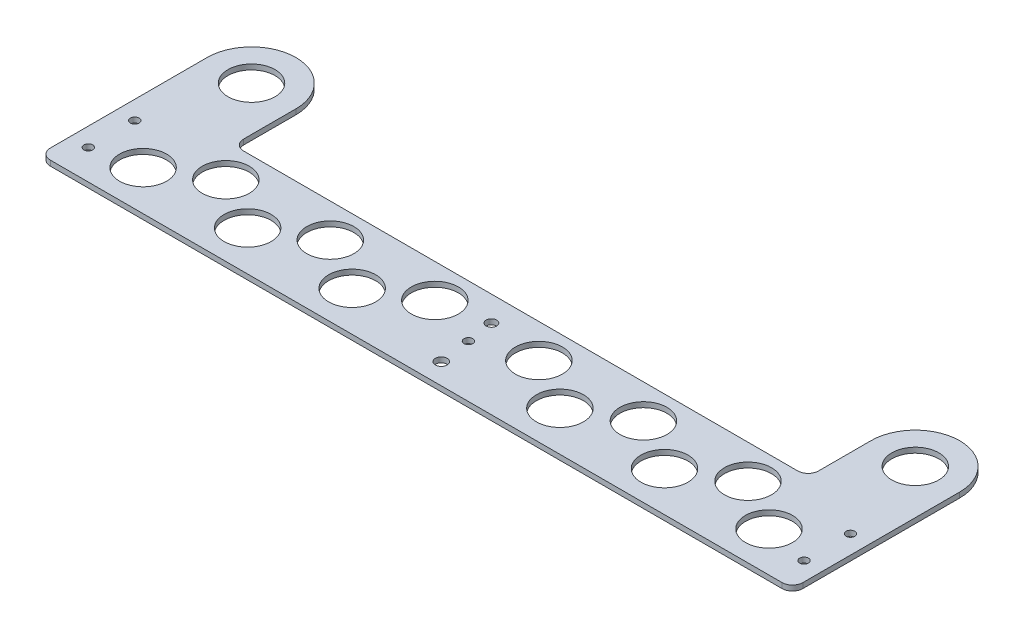
from build123d import *

# Parameters (mm, degrees)
SKETCH1_R           = 14.2875
BOSS_EXTRUDE1_DEPTH = 3.175
CUT_EXTRUDE1_REACH  = 5.175
SKETCH2_R           = 3.556
SKETCH2_R_2         = 3.175
CUT_EXTRUDE2_REACH  = 5.175
SKETCH3_R           = 2.667
CUT_EXTRUDE3_REACH  = 5.175
SKETCH4_R           = 2.667
CUT_EXTRUDE4_REACH  = 5.175
SKETCH6_R           = 14.2875


with BuildPart() as part:
    # Sketch1 → Boss-Extrude1 (new body)
    with BuildSketch(Plane(origin=(0, 0, 0), x_dir=(1, 0, 0), z_dir=(0, 1, 0))):
        with BuildLine():
            Line((-26.9875, 0), (-26.9875, -95.25))
            ThreePointArc((-26.9875, -95.25), (-25.127628061, -99.740128061), (-20.6375, -101.6))
            Line((-20.6375, -101.6), (423.8625, -101.6))
            ThreePointArc((423.8625, -101.6), (428.352628061, -99.740128061), (430.2125, -95.25))
            Line((430.2125, -95.25), (430.2125, 0))
            ThreePointArc((430.2125, 0), (403.225, 26.9875), (376.2375, 0))
            Line((376.2375, 0), (376.2375, -31.75))
            ThreePointArc((376.2375, -31.75), (374.377628061, -36.240128061), (369.8875, -38.1))
            Line((369.8875, -38.1), (33.3375, -38.1))
            ThreePointArc((33.3375, -38.1), (28.847371939, -36.240128061), (26.9875, -31.75))
            Line((26.9875, -31.75), (26.9875, 0))
            ThreePointArc((26.9875, 0), (0, 26.9875), (-26.9875, 0))
        make_face()
        Circle(SKETCH1_R, mode=Mode.SUBTRACT)
        with Locations((403.225, 0)):
            Circle(SKETCH1_R, mode=Mode.SUBTRACT)
    extrude(amount=BOSS_EXTRUDE1_DEPTH)

    # Sketch2 → Cut-Extrude1 (cut, up to next)
    with BuildSketch(Plane(origin=(0, 3.175, 0), x_dir=(1, 0, 0), z_dir=(0, 1, 0)), mode=Mode.PRIVATE) as cut_extrude1_sk1:
        with Locations((204.1525, -88.9)):
            Circle(SKETCH2_R)
    cut_extrude1_tool1 = extrude(cut_extrude1_sk1.sketch, amount=-CUT_EXTRUDE1_REACH, mode=Mode.PRIVATE) & part.part
    add(cut_extrude1_tool1.solids().sort_by_distance((204.1525, 3.175, 88.9))[0], mode=Mode.SUBTRACT)
    # Sketch2 → Cut-Extrude1 (cut, up to next)
    with BuildSketch(Plane(origin=(0, 3.175, 0), x_dir=(1, 0, 0), z_dir=(0, 1, 0)), mode=Mode.PRIVATE) as cut_extrude1_sk2:
        with Locations((199.0725, -53.34)):
            Circle(SKETCH2_R_2)
    cut_extrude1_tool2 = extrude(cut_extrude1_sk2.sketch, amount=-CUT_EXTRUDE1_REACH, mode=Mode.PRIVATE) & part.part
    add(cut_extrude1_tool2.solids().sort_by_distance((199.0725, 3.175, 53.34))[0], mode=Mode.SUBTRACT)

    # Sketch3 → Cut-Extrude2 (cut, up to next)
    with BuildSketch(Plane(origin=(0, 3.175, 0), x_dir=(1, 0, 0), z_dir=(0, 1, 0)), mode=Mode.PRIVATE) as cut_extrude2_sk1:
        with Locations((-15.779743521, -55.159030044)):
            Circle(SKETCH3_R)
    cut_extrude2_tool1 = extrude(cut_extrude2_sk1.sketch, amount=-CUT_EXTRUDE2_REACH, mode=Mode.PRIVATE) & part.part
    add(cut_extrude2_tool1.solids().sort_by_distance((-15.779744, 3.175, 55.15903))[0], mode=Mode.SUBTRACT)
    # Sketch3 → Cut-Extrude2 (cut, up to next)
    with BuildSketch(Plane(origin=(0, 3.175, 0), x_dir=(1, 0, 0), z_dir=(0, 1, 0)), mode=Mode.PRIVATE) as cut_extrude2_sk2:
        with Locations((419.004743521, -55.159030044)):
            Circle(SKETCH3_R)
    cut_extrude2_tool2 = extrude(cut_extrude2_sk2.sketch, amount=-CUT_EXTRUDE2_REACH, mode=Mode.PRIVATE) & part.part
    add(cut_extrude2_tool2.solids().sort_by_distance((419.004744, 3.175, 55.15903))[0], mode=Mode.SUBTRACT)
    # Sketch3 → Cut-Extrude2 (cut, up to next)
    with BuildSketch(Plane(origin=(0, 3.175, 0), x_dir=(1, 0, 0), z_dir=(0, 1, 0)), mode=Mode.PRIVATE) as cut_extrude2_sk3:
        with Locations((-15.779743521, -83.371493131)):
            Circle(SKETCH3_R)
    cut_extrude2_tool3 = extrude(cut_extrude2_sk3.sketch, amount=-CUT_EXTRUDE2_REACH, mode=Mode.PRIVATE) & part.part
    add(cut_extrude2_tool3.solids().sort_by_distance((-15.779744, 3.175, 83.371493))[0], mode=Mode.SUBTRACT)
    # Sketch3 → Cut-Extrude2 (cut, up to next)
    with BuildSketch(Plane(origin=(0, 3.175, 0), x_dir=(1, 0, 0), z_dir=(0, 1, 0)), mode=Mode.PRIVATE) as cut_extrude2_sk4:
        with Locations((419.004743521, -83.371493131)):
            Circle(SKETCH3_R)
    cut_extrude2_tool4 = extrude(cut_extrude2_sk4.sketch, amount=-CUT_EXTRUDE2_REACH, mode=Mode.PRIVATE) & part.part
    add(cut_extrude2_tool4.solids().sort_by_distance((419.004744, 3.175, 83.371493))[0], mode=Mode.SUBTRACT)

    # Sketch4 → Cut-Extrude3 (cut, up to next)
    with BuildSketch(Plane(origin=(0, 3.175, 0), x_dir=(1, 0, 0), z_dir=(0, 1, 0)), mode=Mode.PRIVATE) as cut_extrude3_sk1:
        with Locations((201.6125, -69.85)):
            Circle(SKETCH4_R)
    cut_extrude3_tool1 = extrude(cut_extrude3_sk1.sketch, amount=-CUT_EXTRUDE3_REACH, mode=Mode.PRIVATE) & part.part
    add(cut_extrude3_tool1.solids().sort_by_distance((201.6125, 3.175, 69.85))[0], mode=Mode.SUBTRACT)

    # Sketch6 → Cut-Extrude4 (cut, up to next)
    with BuildSketch(Plane(origin=(0, 3.175, 0), x_dir=(1, 0, 0), z_dir=(0, 1, 0)), mode=Mode.PRIVATE) as cut_extrude4_sk1:
        with Locations((11.501671414, -77.36717452)):
            Circle(SKETCH6_R)
    cut_extrude4_tool1 = extrude(cut_extrude4_sk1.sketch, amount=-CUT_EXTRUDE4_REACH, mode=Mode.PRIVATE) & part.part
    add(cut_extrude4_tool1.solids().sort_by_distance((11.501671, 3.175, 77.367175))[0], mode=Mode.SUBTRACT)
    # Sketch6 → Cut-Extrude4 (cut, up to next)
    with BuildSketch(Plane(origin=(0, 3.175, 0), x_dir=(1, 0, 0), z_dir=(0, 1, 0)), mode=Mode.PRIVATE) as cut_extrude4_sk2:
        with Locations((43.002904056, -58.635968615)):
            Circle(SKETCH6_R)
    cut_extrude4_tool2 = extrude(cut_extrude4_sk2.sketch, amount=-CUT_EXTRUDE4_REACH, mode=Mode.PRIVATE) & part.part
    add(cut_extrude4_tool2.solids().sort_by_distance((43.002904, 3.175, 58.635969))[0], mode=Mode.SUBTRACT)
    # Sketch6 → Cut-Extrude4 (cut, up to next)
    with BuildSketch(Plane(origin=(0, 3.175, 0), x_dir=(1, 0, 0), z_dir=(0, 1, 0)), mode=Mode.PRIVATE) as cut_extrude4_sk3:
        with Locations((75.001671414, -77.36717452)):
            Circle(SKETCH6_R)
    cut_extrude4_tool3 = extrude(cut_extrude4_sk3.sketch, amount=-CUT_EXTRUDE4_REACH, mode=Mode.PRIVATE) & part.part
    add(cut_extrude4_tool3.solids().sort_by_distance((75.001671, 3.175, 77.367175))[0], mode=Mode.SUBTRACT)
    # Sketch6 → Cut-Extrude4 (cut, up to next)
    with BuildSketch(Plane(origin=(0, 3.175, 0), x_dir=(1, 0, 0), z_dir=(0, 1, 0)), mode=Mode.PRIVATE) as cut_extrude4_sk4:
        with Locations((106.502904056, -58.635968615)):
            Circle(SKETCH6_R)
    cut_extrude4_tool4 = extrude(cut_extrude4_sk4.sketch, amount=-CUT_EXTRUDE4_REACH, mode=Mode.PRIVATE) & part.part
    add(cut_extrude4_tool4.solids().sort_by_distance((106.502904, 3.175, 58.635969))[0], mode=Mode.SUBTRACT)
    # Sketch6 → Cut-Extrude4 (cut, up to next)
    with BuildSketch(Plane(origin=(0, 3.175, 0), x_dir=(1, 0, 0), z_dir=(0, 1, 0)), mode=Mode.PRIVATE) as cut_extrude4_sk5:
        with Locations((138.501671414, -77.36717452)):
            Circle(SKETCH6_R)
    cut_extrude4_tool5 = extrude(cut_extrude4_sk5.sketch, amount=-CUT_EXTRUDE4_REACH, mode=Mode.PRIVATE) & part.part
    add(cut_extrude4_tool5.solids().sort_by_distance((138.501671, 3.175, 77.367175))[0], mode=Mode.SUBTRACT)
    # Sketch6 → Cut-Extrude4 (cut, up to next)
    with BuildSketch(Plane(origin=(0, 3.175, 0), x_dir=(1, 0, 0), z_dir=(0, 1, 0)), mode=Mode.PRIVATE) as cut_extrude4_sk6:
        with Locations((170.002904056, -58.635968615)):
            Circle(SKETCH6_R)
    cut_extrude4_tool6 = extrude(cut_extrude4_sk6.sketch, amount=-CUT_EXTRUDE4_REACH, mode=Mode.PRIVATE) & part.part
    add(cut_extrude4_tool6.solids().sort_by_distance((170.002904, 3.175, 58.635969))[0], mode=Mode.SUBTRACT)
    # Sketch6 → Cut-Extrude4 (cut, up to next)
    with BuildSketch(Plane(origin=(0, 3.175, 0), x_dir=(1, 0, 0), z_dir=(0, 1, 0)), mode=Mode.PRIVATE) as cut_extrude4_sk7:
        with Locations((233.222095944, -58.635968615)):
            Circle(SKETCH6_R)
    cut_extrude4_tool7 = extrude(cut_extrude4_sk7.sketch, amount=-CUT_EXTRUDE4_REACH, mode=Mode.PRIVATE) & part.part
    add(cut_extrude4_tool7.solids().sort_by_distance((233.222096, 3.175, 58.635969))[0], mode=Mode.SUBTRACT)
    # Sketch6 → Cut-Extrude4 (cut, up to next)
    with BuildSketch(Plane(origin=(0, 3.175, 0), x_dir=(1, 0, 0), z_dir=(0, 1, 0)), mode=Mode.PRIVATE) as cut_extrude4_sk8:
        with Locations((264.723328586, -77.36717452)):
            Circle(SKETCH6_R)
    cut_extrude4_tool8 = extrude(cut_extrude4_sk8.sketch, amount=-CUT_EXTRUDE4_REACH, mode=Mode.PRIVATE) & part.part
    add(cut_extrude4_tool8.solids().sort_by_distance((264.723329, 3.175, 77.367175))[0], mode=Mode.SUBTRACT)
    # Sketch6 → Cut-Extrude4 (cut, up to next)
    with BuildSketch(Plane(origin=(0, 3.175, 0), x_dir=(1, 0, 0), z_dir=(0, 1, 0)), mode=Mode.PRIVATE) as cut_extrude4_sk9:
        with Locations((296.722095944, -58.635968615)):
            Circle(SKETCH6_R)
    cut_extrude4_tool9 = extrude(cut_extrude4_sk9.sketch, amount=-CUT_EXTRUDE4_REACH, mode=Mode.PRIVATE) & part.part
    add(cut_extrude4_tool9.solids().sort_by_distance((296.722096, 3.175, 58.635969))[0], mode=Mode.SUBTRACT)
    # Sketch6 → Cut-Extrude4 (cut, up to next)
    with BuildSketch(Plane(origin=(0, 3.175, 0), x_dir=(1, 0, 0), z_dir=(0, 1, 0)), mode=Mode.PRIVATE) as cut_extrude4_sk10:
        with Locations((328.223328586, -77.36717452)):
            Circle(SKETCH6_R)
    cut_extrude4_tool10 = extrude(cut_extrude4_sk10.sketch, amount=-CUT_EXTRUDE4_REACH, mode=Mode.PRIVATE) & part.part
    add(cut_extrude4_tool10.solids().sort_by_distance((328.223329, 3.175, 77.367175))[0], mode=Mode.SUBTRACT)
    # Sketch6 → Cut-Extrude4 (cut, up to next)
    with BuildSketch(Plane(origin=(0, 3.175, 0), x_dir=(1, 0, 0), z_dir=(0, 1, 0)), mode=Mode.PRIVATE) as cut_extrude4_sk11:
        with Locations((360.222095944, -58.635968615)):
            Circle(SKETCH6_R)
    cut_extrude4_tool11 = extrude(cut_extrude4_sk11.sketch, amount=-CUT_EXTRUDE4_REACH, mode=Mode.PRIVATE) & part.part
    add(cut_extrude4_tool11.solids().sort_by_distance((360.222096, 3.175, 58.635969))[0], mode=Mode.SUBTRACT)
    # Sketch6 → Cut-Extrude4 (cut, up to next)
    with BuildSketch(Plane(origin=(0, 3.175, 0), x_dir=(1, 0, 0), z_dir=(0, 1, 0)), mode=Mode.PRIVATE) as cut_extrude4_sk12:
        with Locations((391.723328586, -77.36717452)):
            Circle(SKETCH6_R)
    cut_extrude4_tool12 = extrude(cut_extrude4_sk12.sketch, amount=-CUT_EXTRUDE4_REACH, mode=Mode.PRIVATE) & part.part
    add(cut_extrude4_tool12.solids().sort_by_distance((391.723329, 3.175, 77.367175))[0], mode=Mode.SUBTRACT)


solid = part.part
